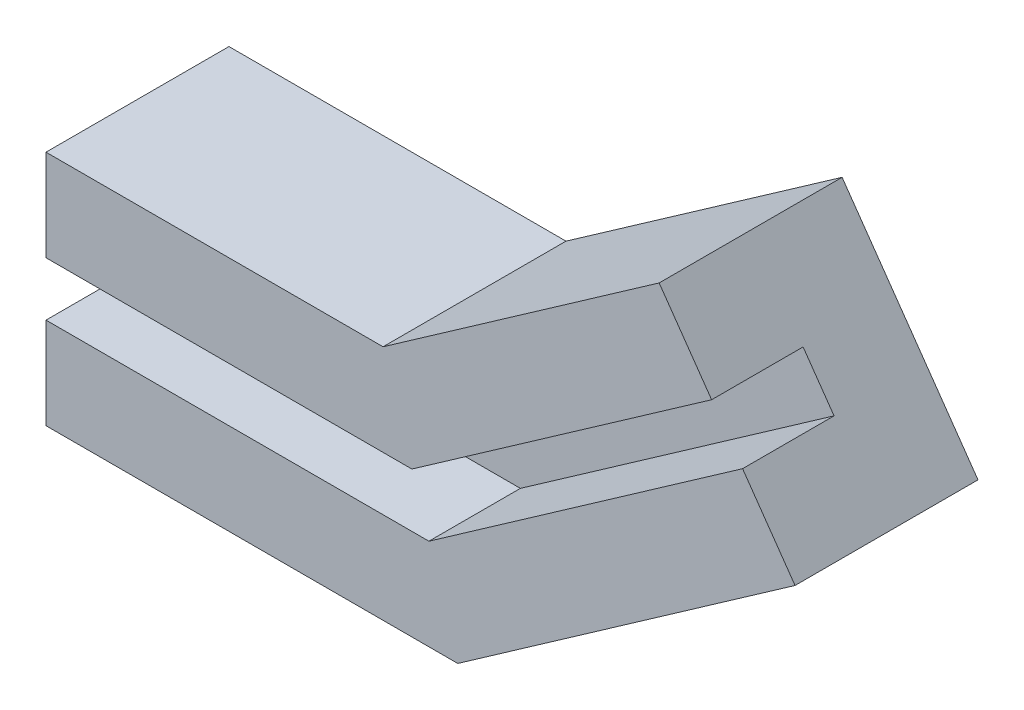
from build123d import *

# Parameters (mm, degrees)
AUFSATZ_LINEAR_AUSTRAGEN2_DEPTH   = 10
AUFSATZ_LINEAR_AUSTRAGEN2_2_DEPTH = 10
AUFSATZ_LINEAR_AUSTRAGEN3_DEPTH   = 10


with BuildPart() as part:
    # Skizze1 → Aufsatz-Linear austragen2 (new body)
    with BuildSketch(Plane.XY):
        Polygon((-10, 5.9), (0, 5.9), (30, 5.9), (54.574561329, 23.107293091), (62.766081772, 28.843057454), (57.030317408, 37.034577897), (26.847012111, 15.9), (-10, 15.9), align=None)
    extrude(amount=AUFSATZ_LINEAR_AUSTRAGEN2_DEPTH)



with BuildPart() as body_2:
    # Skizze1 → Aufsatz-Linear austragen2 2 (new body)
    with BuildSketch(Plane.XY):
        Polygon((31.860262854, 0), (0, 0), (-10, 0), (-10, -10), (35.013250743, -10), (71.88594711, 15.81853995), (66.150182746, 24.010060393), (57.958662303, 18.274296029), align=None)
    extrude(amount=AUFSATZ_LINEAR_AUSTRAGEN2_2_DEPTH)


with BuildPart() as part_1:
    add(part.part)

    add(body_2.part)  # Aufsatz-Linear austragen3 merges body 2
    # Skizze2 → Aufsatz-Linear austragen3 (add)
    with BuildSketch(Plane(origin=(0, 0, 0), x_dir=(-1, 0, 0), z_dir=(0, 0, -1))):
        Polygon((10, 15.9), (-26.847012111, 15.9), (-30, 5.9), (10, 5.9), align=None)
        Polygon((10, 5.9), (-30, 5.9), (-35.013250743, -10), (10, -10), align=None)
        Polygon((-30, 5.9), (-62.766081772, 28.843057454), (-71.88594711, 15.81853995), (-35.013250743, -10), align=None)
        Polygon((-26.847012111, 15.9), (-57.030317408, 37.034577897), (-62.766081772, 28.843057454), (-30, 5.9), align=None)
    extrude(amount=AUFSATZ_LINEAR_AUSTRAGEN3_DEPTH)


solid = part_1.part
